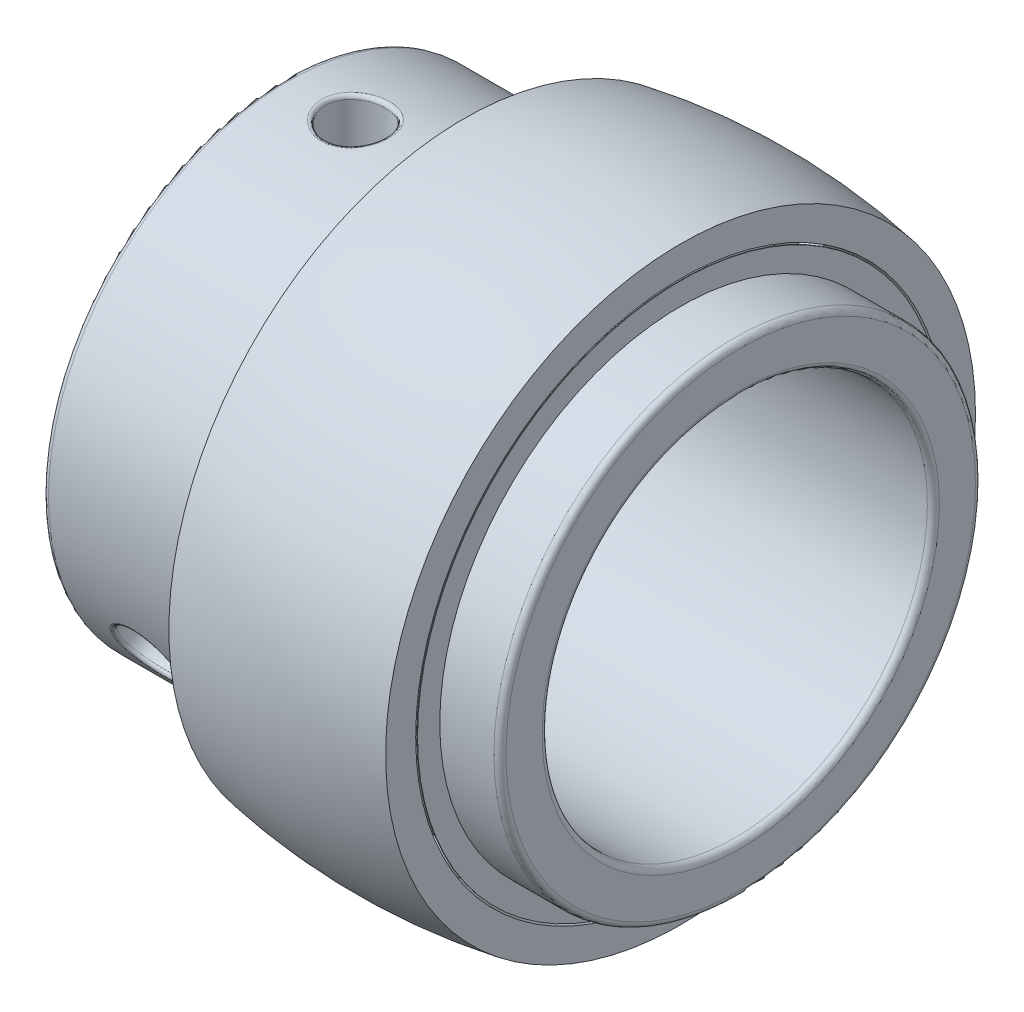
from build123d import *

# Parameters (mm, degrees)
DAIRESEL_KAPLAMA1_COUNT     = 22
IZIM4_R                     = 21.85
IZIM4_R_2                   = 20
Y_KSEKLIK_EKSTR_ZYON1_DEPTH = 0.05
RADYUS1_R                   = 0.5
IZIM5_R                     = 2.5
KES_EKSTR_ZYON1_DEPTH       = 39.05
DAIRESEL_KAPLAMA2_COUNT     = 3
RADYUS2_R                   = 0.3


with BuildPart() as part:
    # Çizim1 → Döndür1 (revolve)
    with BuildSketch(Plane.XY):
        with BuildLine():
            Line((2.291287847, 22), (9, 22))
            Line((9, 22), (9, 24.5))
            ThreePointArc((9, 24.5), (0, 25.281715314), (-9, 24.5))
            Line((-9, 24.5), (-9, 22))
            Line((-9, 22), (-2.291287847, 22))
            ThreePointArc((-2.291287847, 22), (0, 23.5), (2.291287847, 22))
        make_face()
    revolve(axis=Axis((0, 0, 0), (-1, 0, 0)))


with BuildPart() as body_2:
    # Çizim2 → Döndür2 (revolve)
    with BuildSketch(Plane.XY):
        with BuildLine():
            Line((0, -18.5), (0, -23.5))
            ThreePointArc((0, -23.5), (2.5, -21), (0, -18.5))
        make_face()
    revolve(axis=Axis((0, -18.5, 0), (0, -1, 0)))


with BuildPart() as dairesel_kaplama1_1:
    # Dairesel Kaplama1: pattern copy
    add(body_2.part.rotate(Axis((0, 0, 0), (1, 0, 0)), 1 * 360 / DAIRESEL_KAPLAMA1_COUNT))


with BuildPart() as dairesel_kaplama1_2:
    # Dairesel Kaplama1: pattern copy
    add(body_2.part.rotate(Axis((0, 0, 0), (1, 0, 0)), 2 * 360 / DAIRESEL_KAPLAMA1_COUNT))


with BuildPart() as dairesel_kaplama1_3:
    # Dairesel Kaplama1: pattern copy
    add(body_2.part.rotate(Axis((0, 0, 0), (1, 0, 0)), 3 * 360 / DAIRESEL_KAPLAMA1_COUNT))


with BuildPart() as dairesel_kaplama1_4:
    # Dairesel Kaplama1: pattern copy
    add(body_2.part.rotate(Axis((0, 0, 0), (1, 0, 0)), 4 * 360 / DAIRESEL_KAPLAMA1_COUNT))


with BuildPart() as dairesel_kaplama1_5:
    # Dairesel Kaplama1: pattern copy
    add(body_2.part.rotate(Axis((0, 0, 0), (1, 0, 0)), 5 * 360 / DAIRESEL_KAPLAMA1_COUNT))


with BuildPart() as dairesel_kaplama1_6:
    # Dairesel Kaplama1: pattern copy
    add(body_2.part.rotate(Axis((0, 0, 0), (1, 0, 0)), 6 * 360 / DAIRESEL_KAPLAMA1_COUNT))


with BuildPart() as dairesel_kaplama1_7:
    # Dairesel Kaplama1: pattern copy
    add(body_2.part.rotate(Axis((0, 0, 0), (1, 0, 0)), 7 * 360 / DAIRESEL_KAPLAMA1_COUNT))


with BuildPart() as dairesel_kaplama1_8:
    # Dairesel Kaplama1: pattern copy
    add(body_2.part.rotate(Axis((0, 0, 0), (1, 0, 0)), 8 * 360 / DAIRESEL_KAPLAMA1_COUNT))


with BuildPart() as dairesel_kaplama1_9:
    # Dairesel Kaplama1: pattern copy
    add(body_2.part.rotate(Axis((0, 0, 0), (1, 0, 0)), 9 * 360 / DAIRESEL_KAPLAMA1_COUNT))


with BuildPart() as dairesel_kaplama1_10:
    # Dairesel Kaplama1: pattern copy
    add(body_2.part.rotate(Axis((0, 0, 0), (1, 0, 0)), 10 * 360 / DAIRESEL_KAPLAMA1_COUNT))


with BuildPart() as dairesel_kaplama1_11:
    # Dairesel Kaplama1: pattern copy
    add(body_2.part.rotate(Axis((0, 0, 0), (1, 0, 0)), 11 * 360 / DAIRESEL_KAPLAMA1_COUNT))


with BuildPart() as dairesel_kaplama1_12:
    # Dairesel Kaplama1: pattern copy
    add(body_2.part.rotate(Axis((0, 0, 0), (1, 0, 0)), 12 * 360 / DAIRESEL_KAPLAMA1_COUNT))


with BuildPart() as dairesel_kaplama1_13:
    # Dairesel Kaplama1: pattern copy
    add(body_2.part.rotate(Axis((0, 0, 0), (1, 0, 0)), 13 * 360 / DAIRESEL_KAPLAMA1_COUNT))


with BuildPart() as dairesel_kaplama1_14:
    # Dairesel Kaplama1: pattern copy
    add(body_2.part.rotate(Axis((0, 0, 0), (1, 0, 0)), 14 * 360 / DAIRESEL_KAPLAMA1_COUNT))


with BuildPart() as dairesel_kaplama1_15:
    # Dairesel Kaplama1: pattern copy
    add(body_2.part.rotate(Axis((0, 0, 0), (1, 0, 0)), 15 * 360 / DAIRESEL_KAPLAMA1_COUNT))


with BuildPart() as dairesel_kaplama1_16:
    # Dairesel Kaplama1: pattern copy
    add(body_2.part.rotate(Axis((0, 0, 0), (1, 0, 0)), 16 * 360 / DAIRESEL_KAPLAMA1_COUNT))


with BuildPart() as dairesel_kaplama1_17:
    # Dairesel Kaplama1: pattern copy
    add(body_2.part.rotate(Axis((0, 0, 0), (1, 0, 0)), 17 * 360 / DAIRESEL_KAPLAMA1_COUNT))


with BuildPart() as dairesel_kaplama1_18:
    # Dairesel Kaplama1: pattern copy
    add(body_2.part.rotate(Axis((0, 0, 0), (1, 0, 0)), 18 * 360 / DAIRESEL_KAPLAMA1_COUNT))


with BuildPart() as dairesel_kaplama1_19:
    # Dairesel Kaplama1: pattern copy
    add(body_2.part.rotate(Axis((0, 0, 0), (1, 0, 0)), 19 * 360 / DAIRESEL_KAPLAMA1_COUNT))


with BuildPart() as dairesel_kaplama1_20:
    # Dairesel Kaplama1: pattern copy
    add(body_2.part.rotate(Axis((0, 0, 0), (1, 0, 0)), 20 * 360 / DAIRESEL_KAPLAMA1_COUNT))


with BuildPart() as dairesel_kaplama1_21:
    # Dairesel Kaplama1: pattern copy
    add(body_2.part.rotate(Axis((0, 0, 0), (1, 0, 0)), 21 * 360 / DAIRESEL_KAPLAMA1_COUNT))


with BuildPart() as body_24:
    # Çizim3 → Döndür3 (revolve)
    with BuildSketch(Plane.XY):
        with BuildLine():
            Line((-24, 20), (-2.291287847, 20))
            ThreePointArc((-2.291287847, 20), (0, 18.5), (2.291287847, 20))
            Line((2.291287847, 20), (14, 20))
            Line((14, 20), (14, 16))
            Line((14, 16), (-24, 16))
            Line((-24, 16), (-24, 20))
        make_face()
    revolve(axis=Axis((0, 0, 0), (-1, 0, 0)))

    # Çizim4 → Yükseklik-Ekstrüzyon1 (add)
    with BuildSketch(Plane.ZY.offset(9)):
        Circle(IZIM4_R)
        Circle(IZIM4_R_2, mode=Mode.SUBTRACT)
    y_kseklik_ekstr_zyon1 = extrude(amount=-Y_KSEKLIK_EKSTR_ZYON1_DEPTH)

    # Aynalama1: Yükseklik-Ekstrüzyon1 across plane
    add(y_kseklik_ekstr_zyon1.mirror(Plane(origin=(0, 0, 0), x_dir=(0, 0, 1), z_dir=(1, 0, 0))))

    # Radyus1
    radyus1_edges = [body_24.edges().sort_by_distance(p)[0] for p in [
        (-24, -20, 0),
        (14, -20, 0),
        (14, -16, 0),
        (-24, -16, 0),
    ]]
    fillet(radyus1_edges, radius=RADYUS1_R)

    # Çizim5 → Kes-Ekstrüzyon1 (cut)
    with BuildSketch(Plane(origin=(0, 0, 0), x_dir=(1, 0, 0), z_dir=(0, 1, 0))):
        with Locations((-18, 0)):
            Circle(IZIM5_R)
    kes_ekstr_zyon1 = extrude(amount=KES_EKSTR_ZYON1_DEPTH, mode=Mode.SUBTRACT)

    # Dairesel Kaplama2: Kes-Ekstrüzyon1 ×3 about axis
    dairesel_kaplama2_axis = Axis((-24, 0, 0), (-1, 0, 0))
    for i in range(1, DAIRESEL_KAPLAMA2_COUNT):
        add(kes_ekstr_zyon1.rotate(dairesel_kaplama2_axis, i * 360 / DAIRESEL_KAPLAMA2_COUNT), mode=Mode.SUBTRACT)

    # Radyus2
    radyus2_edges = [body_24.edges().sort_by_distance(p)[0] for p in [
        (-18, 15.803480629, 2.5),
        (-18, 19.843134833, 2.5),
        (-20.500000017, -8, 13.856406461),
        (-20.500000016, -10, 17.320508077),
        (-20.500000017, -8.000000001, -13.856406461),
        (-20.500000016, -10.000000002, -17.320508076),
    ]]
    fillet(radyus2_edges, radius=RADYUS2_R)


solid = Compound([part.part, body_2.part, dairesel_kaplama1_1.part, dairesel_kaplama1_2.part, dairesel_kaplama1_3.part, dairesel_kaplama1_4.part, dairesel_kaplama1_5.part, dairesel_kaplama1_6.part, dairesel_kaplama1_7.part, dairesel_kaplama1_8.part, dairesel_kaplama1_9.part, dairesel_kaplama1_10.part, dairesel_kaplama1_11.part, dairesel_kaplama1_12.part, dairesel_kaplama1_13.part, dairesel_kaplama1_14.part, dairesel_kaplama1_15.part, dairesel_kaplama1_16.part, dairesel_kaplama1_17.part, dairesel_kaplama1_18.part, dairesel_kaplama1_19.part, dairesel_kaplama1_20.part, dairesel_kaplama1_21.part, body_24.part])
